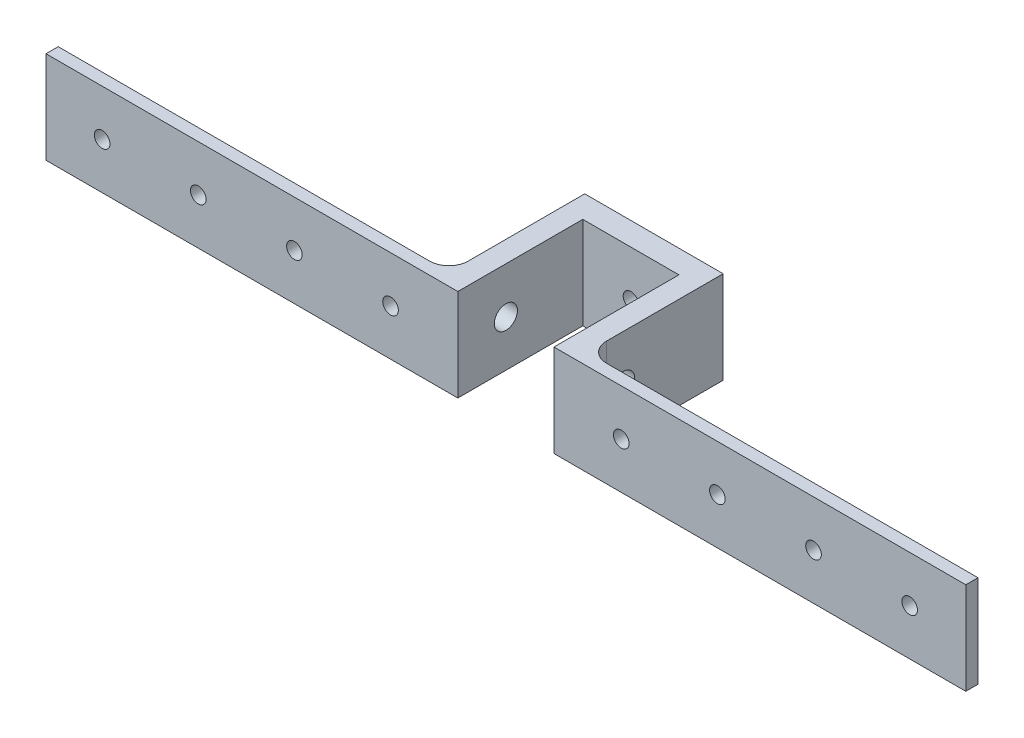
from build123d import *

# Parameters (mm, degrees)
BOSS_EXTRUDE1_DEPTH     = 24
SKETCH2_R               = 2
CUT_EXTRUDE1_DEPTH      = 24
SKETCH3_R               = 3
CUT_EXTRUDE2_DEPTH      = 1
CUT_EXTRUDE2_DEPTH_BACK = 37
SKETCH4_W               = 3.175
SKETCH4_H               = 24
BOSS_EXTRUDE2_DEPTH     = 101.6
SKETCH7_R               = 2.032
CUT_EXTRUDE3_DEPTH      = 4.175
FILLET1_R               = 5
FILLET2_R               = 5


with BuildPart() as part:
    # Sketch1 → Boss-Extrude1 (new body)
    with BuildSketch(Plane(origin=(0, 0, 0), x_dir=(1, 0, 0), z_dir=(0, 1, 0))):
        Polygon((12.5, -16.134036145), (12.5, 16.365963855), (-12.5, 16.365963855), (-12.5, -16.134036145), (-18, -16.134036145), (-18, 22.365963855), (18, 22.365963855), (18, -16.134036145), align=None)
    extrude(amount=BOSS_EXTRUDE1_DEPTH)

    # Sketch2 → Cut-Extrude1 (cut)
    with BuildSketch(Plane(origin=(0, 0, -22.365963855), x_dir=(-1, 0, 0), z_dir=(0, 0, -1))):
        with Locations((0, 12)):
            Circle(SKETCH2_R)
    extrude(amount=-CUT_EXTRUDE1_DEPTH, mode=Mode.SUBTRACT)

    # Sketch3 → Cut-Extrude2 (cut, two sides)
    with BuildSketch(Plane.ZY.offset(18)) as cut_extrude2_sk:
        with Locations((3.634036145, 12)):
            Circle(SKETCH3_R)
    extrude(amount=CUT_EXTRUDE2_DEPTH, mode=Mode.SUBTRACT)
    extrude(cut_extrude2_sk.sketch, amount=-CUT_EXTRUDE2_DEPTH_BACK, mode=Mode.SUBTRACT)

    # Sketch4 → Boss-Extrude2 (add)
    with BuildSketch(Plane.ZY.offset(18)):
        with Locations((14.546536145, 12)):
            Rectangle(SKETCH4_W, SKETCH4_H)
    boss_extrude2 = extrude(amount=BOSS_EXTRUDE2_DEPTH)

    # Sketch7 → Cut-Extrude3 (cut, through all)
    with BuildSketch(Plane(origin=(0, 0, 12.959036145), x_dir=(-1, 0, 0), z_dir=(0, 0, -1))):
        with Locations((30, 12)):
            Circle(SKETCH7_R)
        with Locations((55, 12)):
            Circle(SKETCH7_R)
        with Locations((80, 12)):
            Circle(SKETCH7_R)
        with Locations((105, 12)):
            Circle(SKETCH7_R)
        with Locations((130, 12)):
            Circle(SKETCH7_R)
        with Locations((155, 12)):
            Circle(SKETCH7_R)
    cut_extrude3 = extrude(amount=-CUT_EXTRUDE3_DEPTH, mode=Mode.SUBTRACT)

    # Mirror1: Boss-Extrude2, Cut-Extrude3 across plane
    add(boss_extrude2.mirror(Plane.ZY))
    add(cut_extrude3.mirror(Plane.ZY), mode=Mode.SUBTRACT)

    # Fillet1
    fillet1_edges = [part.edges().sort_by_distance(p)[0] for p in [
        (-18, 12, 12.959036145),
    ]]
    fillet(fillet1_edges, radius=FILLET1_R)

    # Fillet2
    fillet2_edges = [part.edges().sort_by_distance(p)[0] for p in [
        (18, 12, 12.959036145),
    ]]
    fillet(fillet2_edges, radius=FILLET2_R)


solid = part.part
